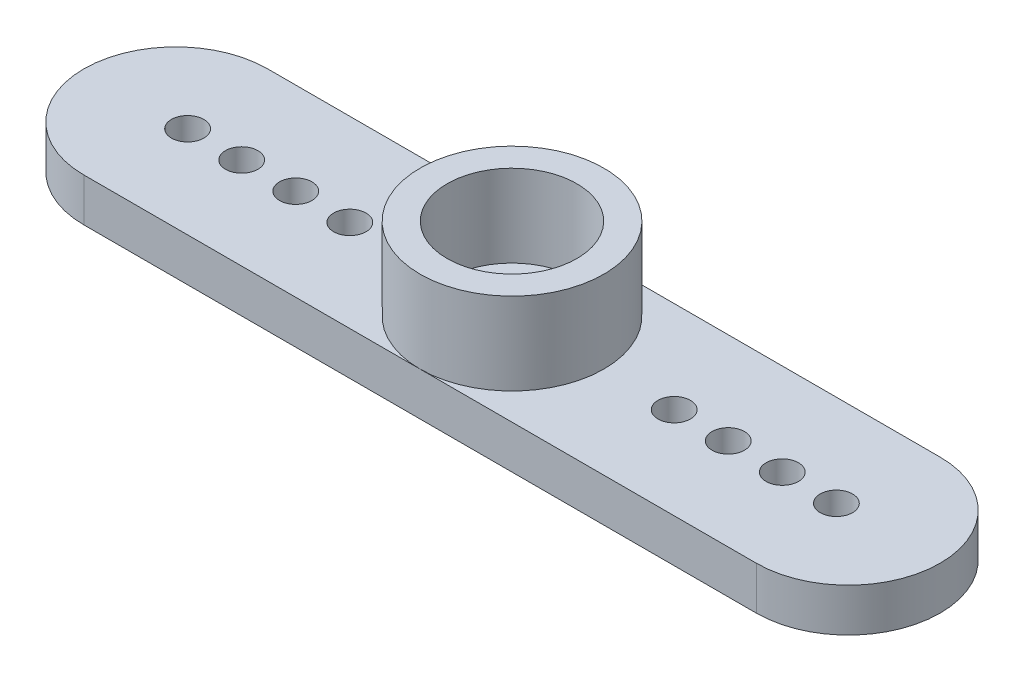
from build123d import *

# Parameters (mm, degrees)
SKETCH_1_R          = 0.75
EXTRUDE_1_DEPTH     = 2
SKETCH_2_R          = 4.25
EXTRUDE_2_DEPTH     = 3.8
SKETCH_3_R          = 3
CUT_EXTRUDE_1_DEPTH = 3.8


with BuildPart() as part:
    # Эскиз1 → Бобышка-Вытянуть1 (new body)
    with BuildSketch(Plane(origin=(0, 0, 0), x_dir=(1, 0, 0), z_dir=(0, 1, 0))):
        with BuildLine():
            Line((0, 4.25), (31.1, 4.25))
            ThreePointArc((31.1, 4.25), (35.35, 0), (31.1, -4.25))
            Line((31.1, -4.25), (0, -4.25))
            ThreePointArc((0, -4.25), (-4.25, 0), (0, 4.25))
        make_face()
        with Locations((8.05, 0)):
            Circle(SKETCH_1_R, mode=Mode.SUBTRACT)
        with Locations((23.05, 0)):
            Circle(SKETCH_1_R, mode=Mode.SUBTRACT)
        with Locations((25.55, 0)):
            Circle(SKETCH_1_R, mode=Mode.SUBTRACT)
        with Locations((28.05, 0)):
            Circle(SKETCH_1_R, mode=Mode.SUBTRACT)
        with Locations((30.55, 0)):
            Circle(SKETCH_1_R, mode=Mode.SUBTRACT)
        with Locations((5.55, 0)):
            Circle(SKETCH_1_R, mode=Mode.SUBTRACT)
        with Locations((3.05, 0)):
            Circle(SKETCH_1_R, mode=Mode.SUBTRACT)
        with Locations((0.55, 0)):
            Circle(SKETCH_1_R, mode=Mode.SUBTRACT)
    extrude(amount=EXTRUDE_1_DEPTH)

    # Эскиз2 → Бобышка-Вытянуть2 (add)
    with BuildSketch(Plane(origin=(0, 2, 0), x_dir=(1, 0, 0), z_dir=(0, 1, 0))):
        with Locations((15.55, 0)):
            Circle(SKETCH_2_R)
    extrude(amount=EXTRUDE_2_DEPTH)

    # Эскиз3 → Вырез-Вытянуть1 (cut)
    with BuildSketch(Plane(origin=(0, 5.8, 0), x_dir=(1, 0, 0), z_dir=(0, 1, 0))):
        with Locations((15.55, 0)):
            Circle(SKETCH_3_R)
    extrude(amount=-CUT_EXTRUDE_1_DEPTH, mode=Mode.SUBTRACT)


solid = part.part
